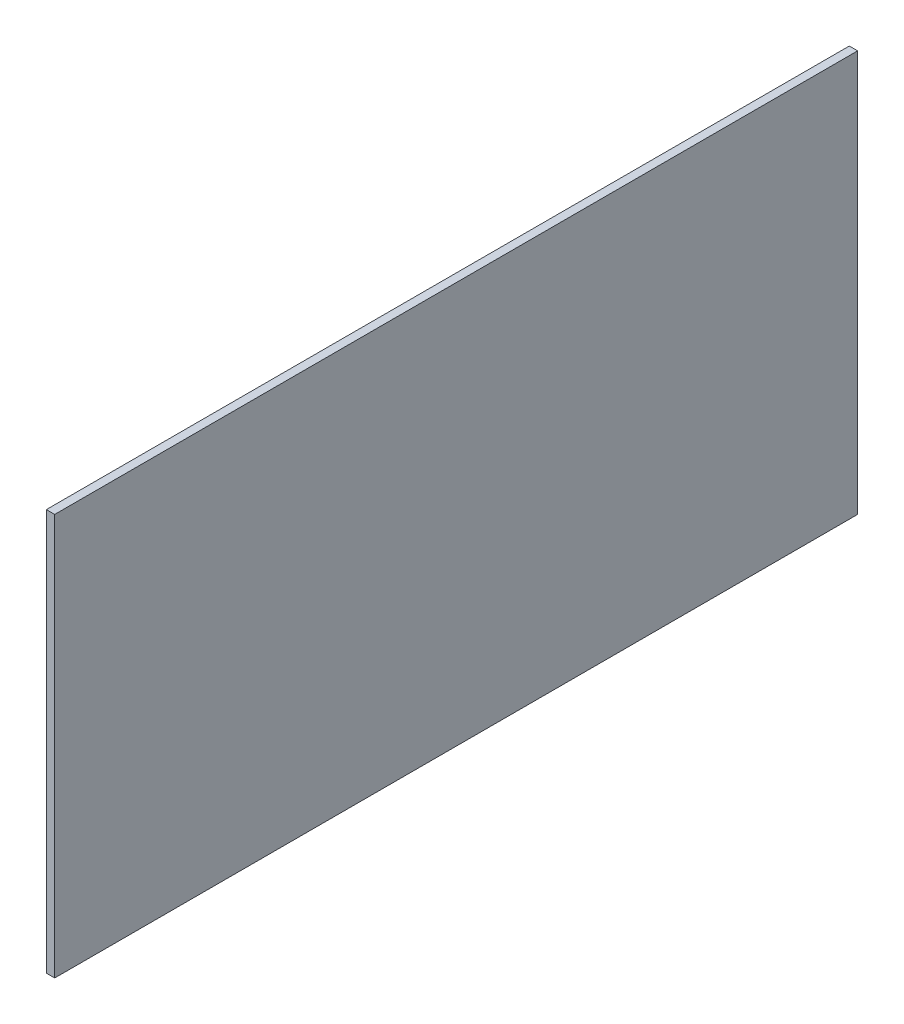
from build123d import *

# Parameters (mm, degrees)
SKETCH1_W           = 152.4
SKETCH1_H           = 76.2
BOSS_EXTRUDE1_DEPTH = 1.5875


with BuildPart() as part:
    # Sketch1 → Boss-Extrude1 (new body)
    with BuildSketch(Plane(origin=(0, 0, 0), x_dir=(0, 0, -1), z_dir=(1, 0, 0))):
        Rectangle(SKETCH1_W, SKETCH1_H)
    extrude(amount=BOSS_EXTRUDE1_DEPTH)


solid = part.part
